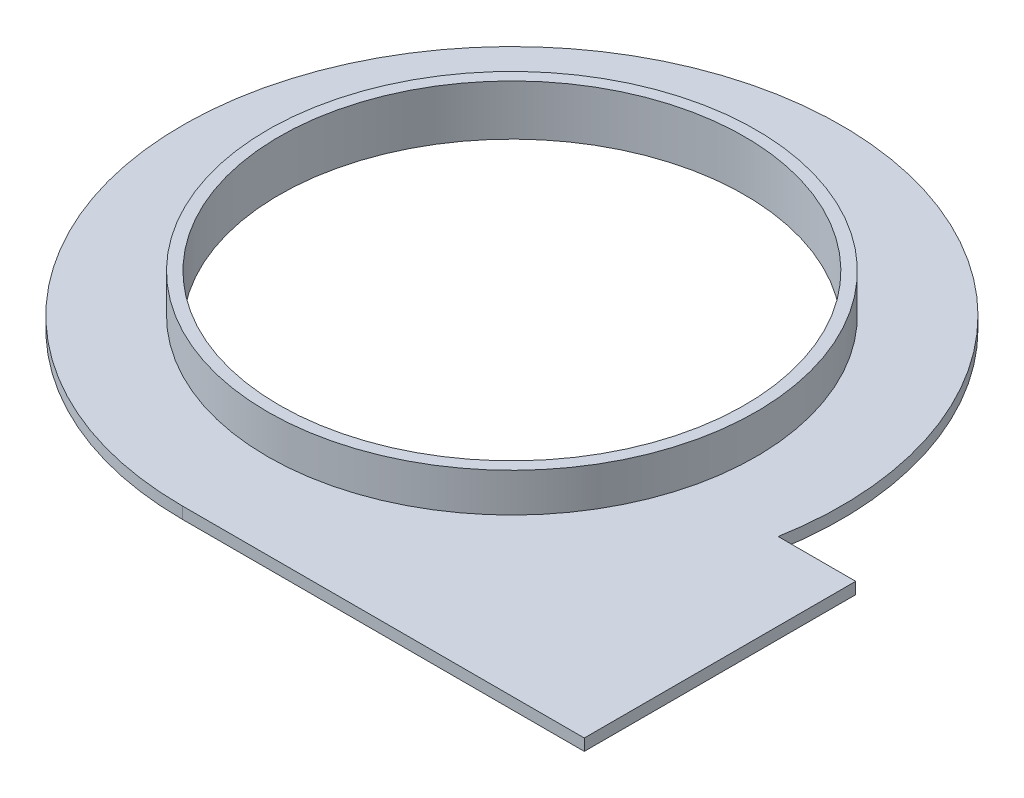
from build123d import *

# Parameters (mm, degrees)
SKETCH2_R           = 60
BOSS_EXTRUDE1_DEPTH = 3
SKETCH3_R           = 63
SKETCH3_R_2         = 60
BOSS_EXTRUDE2_DEPTH = 10


with BuildPart() as part:
    # Sketch2 → Boss-Extrude1 (new body)
    with BuildSketch(Plane(origin=(0, 0, 0), x_dir=(1, 0, 0), z_dir=(0, 1, 0))):
        with BuildLine():
            Line((0, -85), (103.666002653, -85))
            Line((103.666002653, -85), (103.666002653, -15))
            Line((103.666002653, -15), (83.666002653, -15))
            ThreePointArc((83.666002653, -15), (-54.543560573, 65.192024052), (0, -85))
        make_face()
        Circle(SKETCH2_R, mode=Mode.SUBTRACT)
    extrude(amount=BOSS_EXTRUDE1_DEPTH)

    # Sketch3 → Boss-Extrude2 (add)
    with BuildSketch(Plane(origin=(0, 3, 0), x_dir=(1, 0, 0), z_dir=(0, 1, 0))):
        Circle(SKETCH3_R)
        Circle(SKETCH3_R_2, mode=Mode.SUBTRACT)
    extrude(amount=BOSS_EXTRUDE2_DEPTH)


solid = part.part
